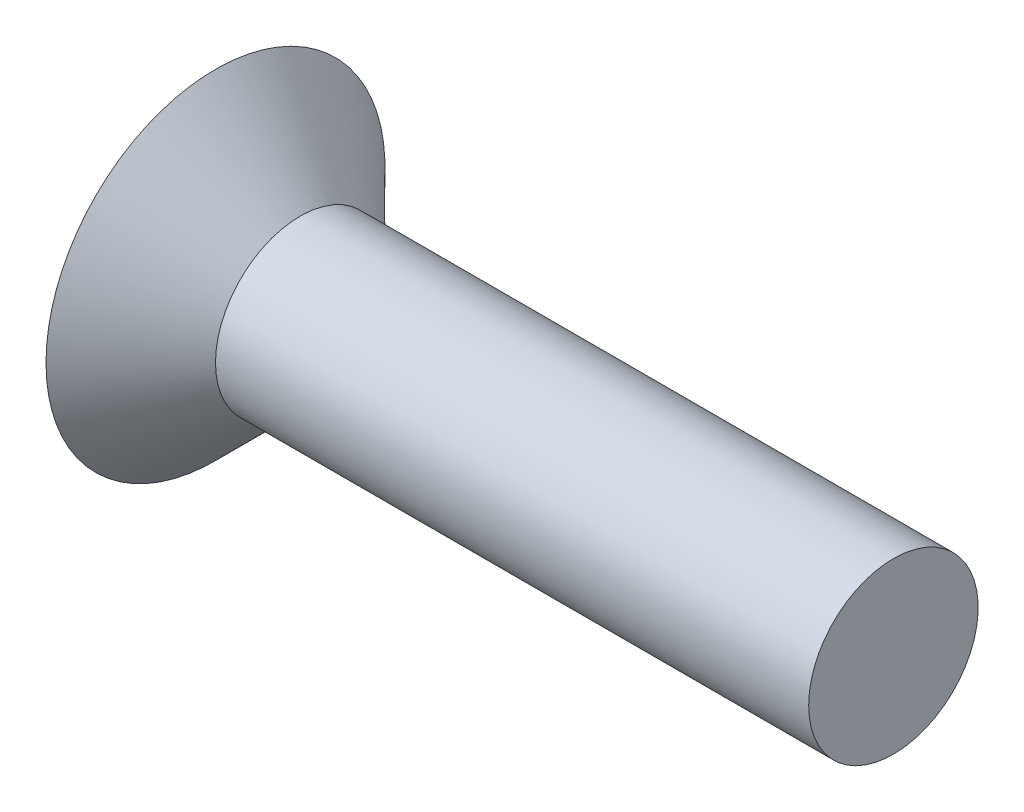
from build123d import *

# Parameters (mm, degrees)
CUT_EXTRUDE_1_DEPTH = 1


with BuildPart() as part:
    # 草图1 → 旋转1 (revolve)
    with BuildSketch(Plane.XY, mode=Mode.PRIVATE) as revolve_1_sk:
        Polygon((0, 0), (0, 3), (1.5, 1.5), (12, 1.5), (12, 0), align=None)
    revolve(revolve_1_sk.sketch.rotate(Axis((0, 0, 0), (1, 0, 0)), 90), axis=Axis((0, 0, 0), (1, 0, 0)))

    # 草图2 → 切除-拉伸1 (cut)
    with BuildSketch(Plane.ZY):
        Polygon((0, 1.154700538), (-1, 0.577350269), (-1, -0.577350269), (0, -1.154700538), (1, -0.577350269), (1, 0.577350269), align=None)
    extrude(amount=-CUT_EXTRUDE_1_DEPTH, mode=Mode.SUBTRACT)


solid = part.part
